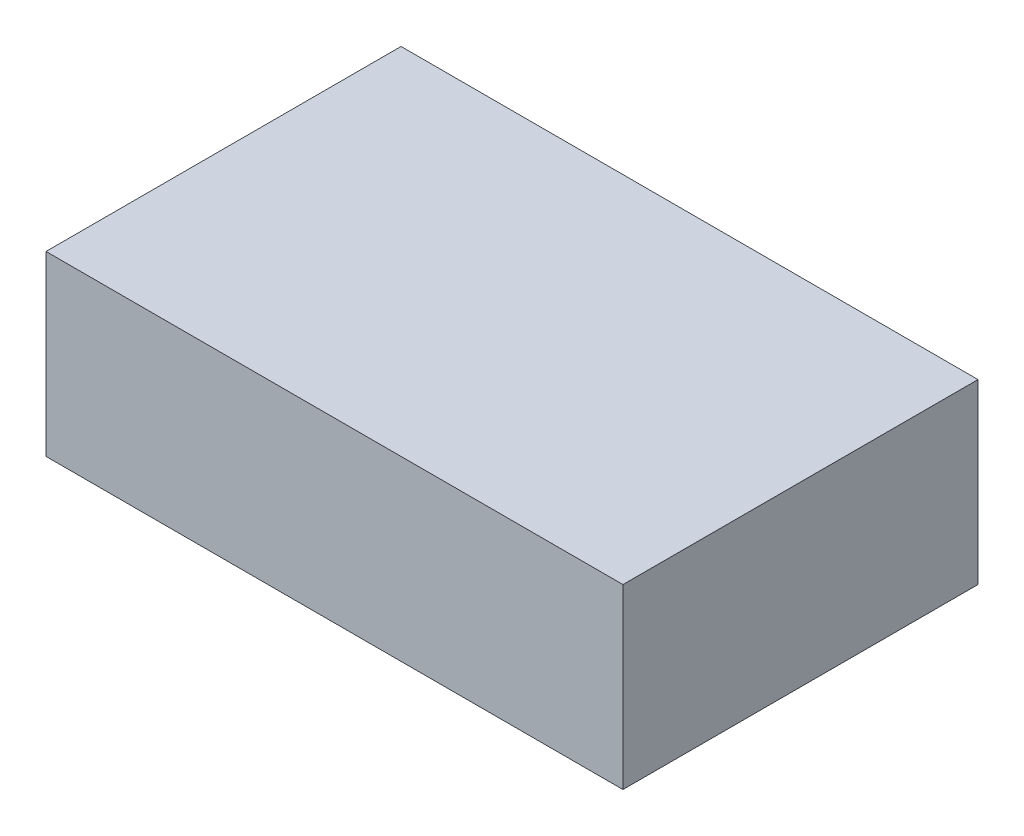
from build123d import *

# Parameters (mm, degrees)
SKETCH1_W           = 130
SKETCH1_H           = 80
BOSS_EXTRUDE1_DEPTH = 40


with BuildPart() as part:
    # Sketch1 → Boss-Extrude1 (new body)
    with BuildSketch(Plane(origin=(0, 0, 0), x_dir=(1, 0, 0), z_dir=(0, 1, 0))):
        Rectangle(SKETCH1_W, SKETCH1_H)
    extrude(amount=BOSS_EXTRUDE1_DEPTH)


solid = part.part
